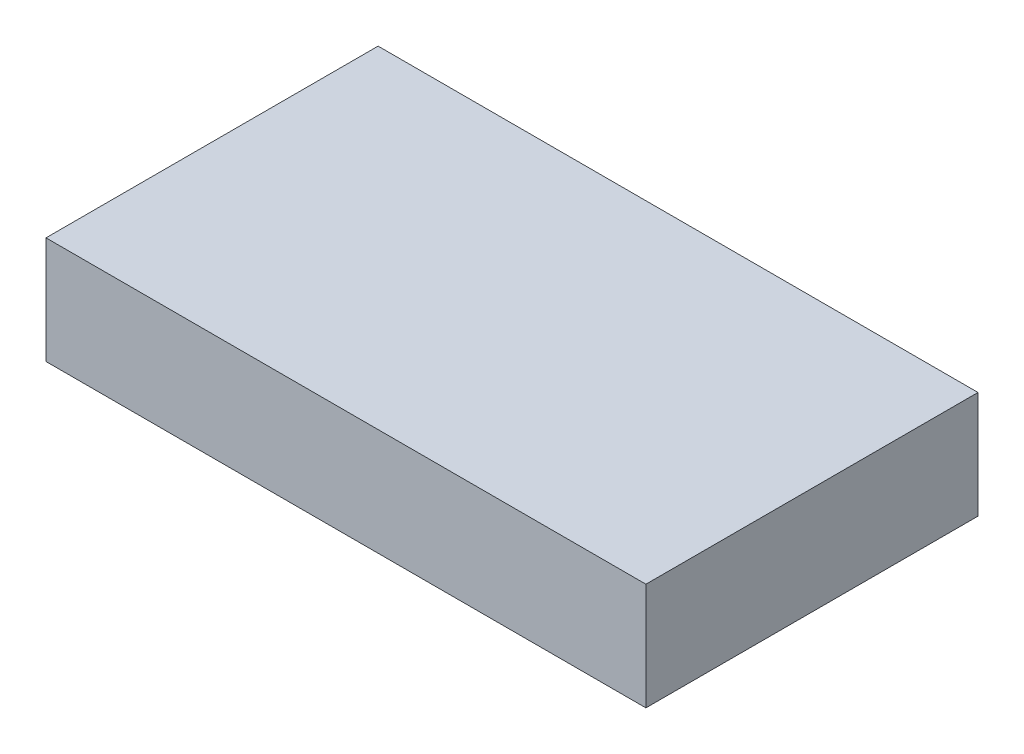
from build123d import *

# Parameters (mm, degrees)
SKETCH1_W           = 56
SKETCH1_H           = 31
BOSS_EXTRUDE1_DEPTH = 10


with BuildPart() as part:
    # Sketch1 → Boss-Extrude1 (new body)
    with BuildSketch(Plane(origin=(0, 0, 0), x_dir=(1, 0, 0), z_dir=(0, 1, 0))):
        Rectangle(SKETCH1_W, SKETCH1_H)
    extrude(amount=BOSS_EXTRUDE1_DEPTH)


solid = part.part
